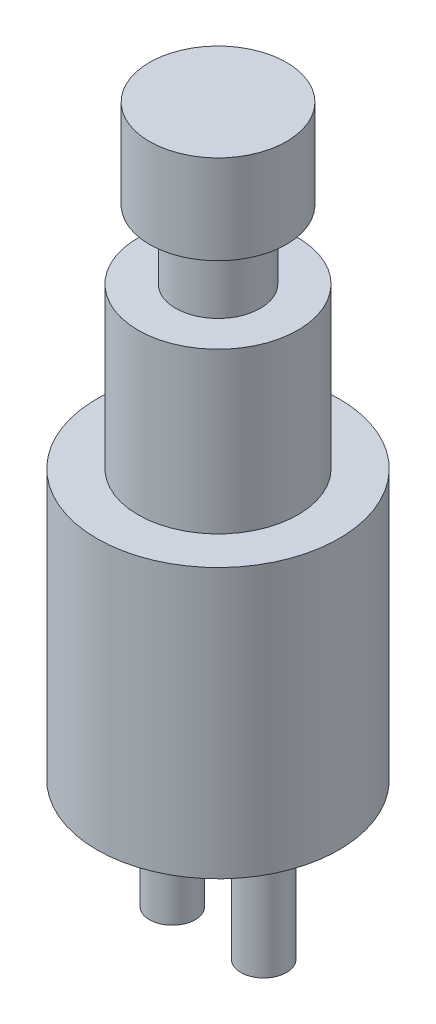
from build123d import *

# Parameters (mm, degrees)
SKETCH2_R           = 5.3
BOSS_EXTRUDE1_DEPTH = 11.8
SKETCH3_R           = 3.5
BOSS_EXTRUDE2_DEPTH = 7
SKETCH4_R           = 1.85
BOSS_EXTRUDE3_DEPTH = 3
SKETCH5_R           = 3
BOSS_EXTRUDE4_DEPTH = 3.9
SKETCH6_R           = 1
BOSS_EXTRUDE5_DEPTH = 5.8


with BuildPart() as part:
    # Sketch2 → Boss-Extrude1 (new body)
    with BuildSketch(Plane(origin=(0, 0, 0), x_dir=(1, 0, 0), z_dir=(0, 1, 0))):
        Circle(SKETCH2_R)
    extrude(amount=BOSS_EXTRUDE1_DEPTH)

    # Sketch3 → Boss-Extrude2 (add)
    with BuildSketch(Plane(origin=(0, 11.8, 0), x_dir=(1, 0, 0), z_dir=(0, 1, 0))):
        Circle(SKETCH3_R)
    extrude(amount=BOSS_EXTRUDE2_DEPTH)

    # Sketch4 → Boss-Extrude3 (add)
    with BuildSketch(Plane(origin=(0, 18.8, 0), x_dir=(1, 0, 0), z_dir=(0, 1, 0))):
        Circle(SKETCH4_R)
    extrude(amount=BOSS_EXTRUDE3_DEPTH)

    # Sketch5 → Boss-Extrude4 (add)
    with BuildSketch(Plane(origin=(0, 21.8, 0), x_dir=(1, 0, 0), z_dir=(0, 1, 0))):
        Circle(SKETCH5_R)
    extrude(amount=BOSS_EXTRUDE4_DEPTH)

    # Sketch6 → Boss-Extrude5 (add)
    with BuildSketch(Plane(origin=(0, 0, 0), x_dir=(-1, 0, 0), z_dir=(0, -1, 0))):
        with Locations((2, 0)):
            Circle(SKETCH6_R)
        with Locations((-2, 0)):
            Circle(SKETCH6_R)
    extrude(amount=BOSS_EXTRUDE5_DEPTH)


solid = part.part
